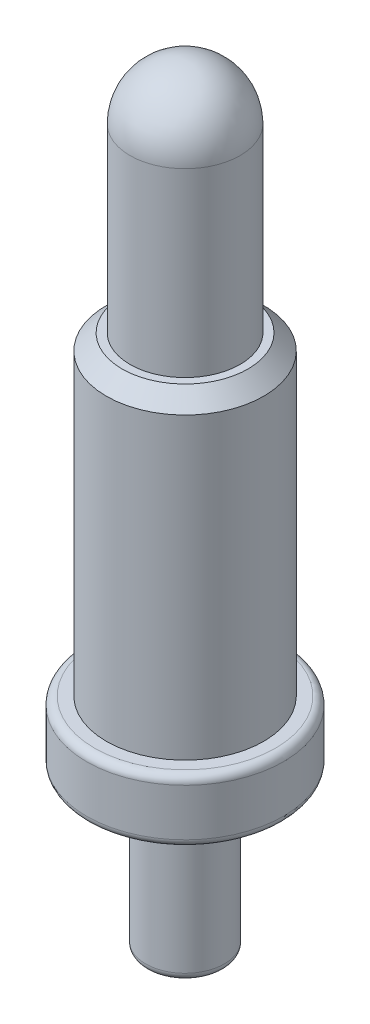
from build123d import *

# Parameters (mm, degrees)
SKETCH_1_R      = 0.5
EXTRUDE_1_DEPTH = 2
SKETCH_2_R      = 1.25
EXTRUDE_2_DEPTH = 0.8
SKETCH_3_R      = 1
EXTRUDE_3_DEPTH = 4
SKETCH_4_R      = 0.7
EXTRUDE_4_DEPTH = 3
FILLET_1_R      = 0.7
CHAMFER_1_SIZE  = 0.2
FILLET_2_R      = 0.1


with BuildPart() as part:
    # 草图1 → 凸台-拉伸1 (new body)
    with BuildSketch(Plane(origin=(0, 0, 0), x_dir=(1, 0, 0), z_dir=(0, 1, 0))):
        Circle(SKETCH_1_R)
    extrude(amount=-EXTRUDE_1_DEPTH)

    # 草图2 → 凸台-拉伸2 (add)
    with BuildSketch(Plane(origin=(0, 0, 0), x_dir=(1, 0, 0), z_dir=(0, 1, 0))):
        Circle(SKETCH_2_R)
    extrude(amount=EXTRUDE_2_DEPTH)

    # 草图3 → 凸台-拉伸3 (add)
    with BuildSketch(Plane(origin=(0, 0.8, 0), x_dir=(1, 0, 0), z_dir=(0, 1, 0))):
        Circle(SKETCH_3_R)
    extrude(amount=EXTRUDE_3_DEPTH)

    # 草图4 → 凸台-拉伸4 (add)
    with BuildSketch(Plane(origin=(0, 4.8, 0), x_dir=(1, 0, 0), z_dir=(0, 1, 0))):
        Circle(SKETCH_4_R)
    extrude(amount=EXTRUDE_4_DEPTH)

    # 圆角1
    fillet_1_edges = [part.edges().sort_by_distance(p)[0] for p in [
        (-0.7, 7.8, 0),
    ]]
    fillet(fillet_1_edges, radius=FILLET_1_R)

    # 倒角1
    chamfer_1_edges = [part.edges().sort_by_distance(p)[0] for p in [
        (-1, 4.8, 0),
    ]]
    chamfer(chamfer_1_edges, length=CHAMFER_1_SIZE)

    # 圆角2
    fillet_2_edges = [part.edges().sort_by_distance(p)[0] for p in [
        (-0.5, -2, 0),
        (-1.25, 0, 0),
        (-1.25, 0.8, 0),
    ]]
    fillet(fillet_2_edges, radius=FILLET_2_R)


solid = part.part
